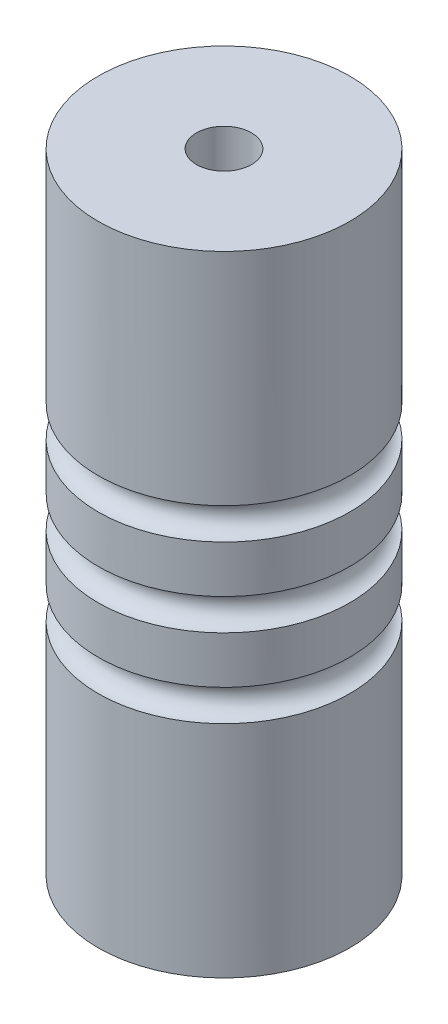
from build123d import *

# Parameters (mm, degrees)
SKETCH1_R      = 8
EXTRUDE1_DEPTH = 40
SKETCH2_R      = 1.75
EXTRUDE2_DEPTH = 40
SKETCH3_R      = 4
EXTRUDE3_DEPTH = 6.35
SKETCH4_R      = 1


with BuildPart() as part:
    # Sketch1 → Extrude1 (new body)
    with BuildSketch(Plane(origin=(0, 0, 0), x_dir=(1, 0, 0), z_dir=(0, 1, 0))):
        Circle(SKETCH1_R)
    extrude(amount=EXTRUDE1_DEPTH)

    # Sketch2 → Extrude2 (cut)
    with BuildSketch(Plane(origin=(0, 40, 0), x_dir=(-1, 0, 0), z_dir=(0, 1, 0))):
        Circle(SKETCH2_R)
    extrude(amount=-EXTRUDE2_DEPTH, mode=Mode.SUBTRACT)

    # Sketch3 → Extrude3 (cut)
    with BuildSketch(Plane.XZ):
        Circle(SKETCH3_R)
    extrude(amount=-EXTRUDE3_DEPTH, mode=Mode.SUBTRACT)

    # Cut-Sweep1: sweep along a path in Sketch6
    with BuildLine(Plane(origin=(0, 15, 0), x_dir=(-1, 0, 0), z_dir=(0, 1, 0))) as cut_sweep1_path:
        CenterArc((0, 0), 8, 0, 360)
    # Sketch4 → Cut-Sweep1 (sweep, cut)
    with BuildSketch(Plane.XY):
        with Locations((8, 20)):
            Circle(SKETCH4_R)
        with Locations((8, 25)):
            Circle(SKETCH4_R)
        with Locations((8, 15)):
            Circle(SKETCH4_R)
    sweep(path=cut_sweep1_path.line, mode=Mode.SUBTRACT)


solid = part.part
